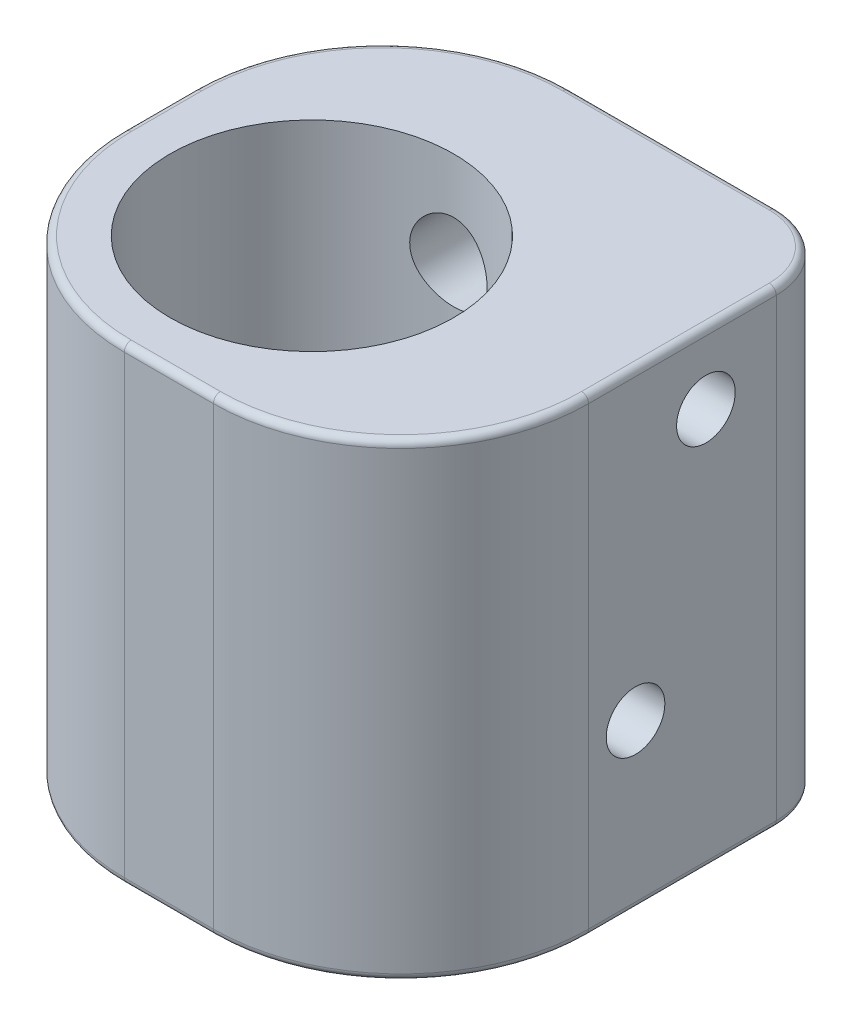
from build123d import *

# Parameters (mm, degrees)
SKETCH_1_R             = 6.05
EXTRUDE_1_DEPTH        = 20
SKETCH_2_R             = 1
CUT_EXTRUDE_1_DEPTH    = 2
HOLE_WIZARD_M3_1_D     = 2.5
HOLE_WIZARD_M3_1_DEPTH = 7
HOLE_WIZARD_M3_1_TIP   = 0.751075774
HOLE_WIZARD_M4_1_D     = 3.3
HOLE_WIZARD_M4_1_DEPTH = 11.5
HOLE_WIZARD_M4_1_TIP   = 0.991420021
FILLET_1_R             = 0.3


with BuildPart() as part:
    # 草图1 → 凸台-拉伸1 (new body)
    with BuildSketch(Plane(origin=(0, 0, 0), x_dir=(1, 0, 0), z_dir=(0, 1, 0))):
        with BuildLine():
            Line((0, 11), (8.8, 11))
            ThreePointArc((8.8, 11), (10.921320344, 10.121320344), (11.8, 8))
            Line((11.8, 8), (11.8, 0))
            ThreePointArc((11.8, 0), (9.456854249, -5.656854249), (3.8, -8))
            Line((3.8, -8), (0, -8))
            ThreePointArc((0, -8), (-5.656854249, -5.656854249), (-8, 0))
            Line((-8, 0), (-8, 3))
            ThreePointArc((-8, 3), (-5.656854249, 8.656854249), (0, 11))
        make_face()
        Circle(SKETCH_1_R, mode=Mode.SUBTRACT)
    extrude(amount=EXTRUDE_1_DEPTH)

    # 草图2 → 切除-拉伸1 (cut)
    with BuildSketch(Plane(origin=(11.8, 0, 0), x_dir=(0, 0, -1), z_dir=(1, 0, 0))):
        with Locations((5, 17)):
            Circle(SKETCH_2_R)
        with Locations((2, 7)):
            Circle(SKETCH_2_R)
    extrude(amount=-CUT_EXTRUDE_1_DEPTH, mode=Mode.SUBTRACT)

    # M3 螺纹孔1
    with Locations(Plane(origin=(11.8, 0, 0), x_dir=(0, 0, -1), z_dir=(1, 0, 0))):
        with Locations((5, 17), (2, 7)):
            Hole(HOLE_WIZARD_M3_1_D / 2, depth=HOLE_WIZARD_M3_1_DEPTH)
            with Locations((0, 0, -(HOLE_WIZARD_M3_1_DEPTH + HOLE_WIZARD_M3_1_TIP / 2))):  # 118° drill point
                Cone(0, HOLE_WIZARD_M3_1_D / 2, HOLE_WIZARD_M3_1_TIP, mode=Mode.SUBTRACT)

    # M4 螺纹孔1
    with Locations(Plane(origin=(3, 0, -11), x_dir=(1, 0, 0), z_dir=(0, 0, -1))):
        with Locations((-3, -16), (-3, -4)):
            Hole(HOLE_WIZARD_M4_1_D / 2, depth=HOLE_WIZARD_M4_1_DEPTH)
            with Locations((0, 0, -(HOLE_WIZARD_M4_1_DEPTH + HOLE_WIZARD_M4_1_TIP / 2))):  # 118° drill point
                Cone(0, HOLE_WIZARD_M4_1_D / 2, HOLE_WIZARD_M4_1_TIP, mode=Mode.SUBTRACT)

    # 圆角1
    fillet_1_edges = [part.edges().sort_by_distance(p)[0] for p in [
        (9.456854249, 0, 5.656854249),
        (1.9, 0, 8),
        (-5.656854249, 0, 5.656854249),
        (-8, 0, -1.5),
        (-5.656854249, 0, -8.656854249),
        (4.4, 0, -11),
        (10.921320344, 0, -10.121320344),
        (9.456854249, 20, 5.656854249),
        (1.9, 20, 8),
        (-5.656854249, 20, 5.656854249),
        (-8, 20, -1.5),
        (-5.656854249, 20, -8.656854249),
        (4.4, 20, -11),
        (10.921320344, 20, -10.121320344),
        (11.8, 0, -4),
        (11.8, 20, -4),
    ]]
    fillet(fillet_1_edges, radius=FILLET_1_R)


solid = part.part
